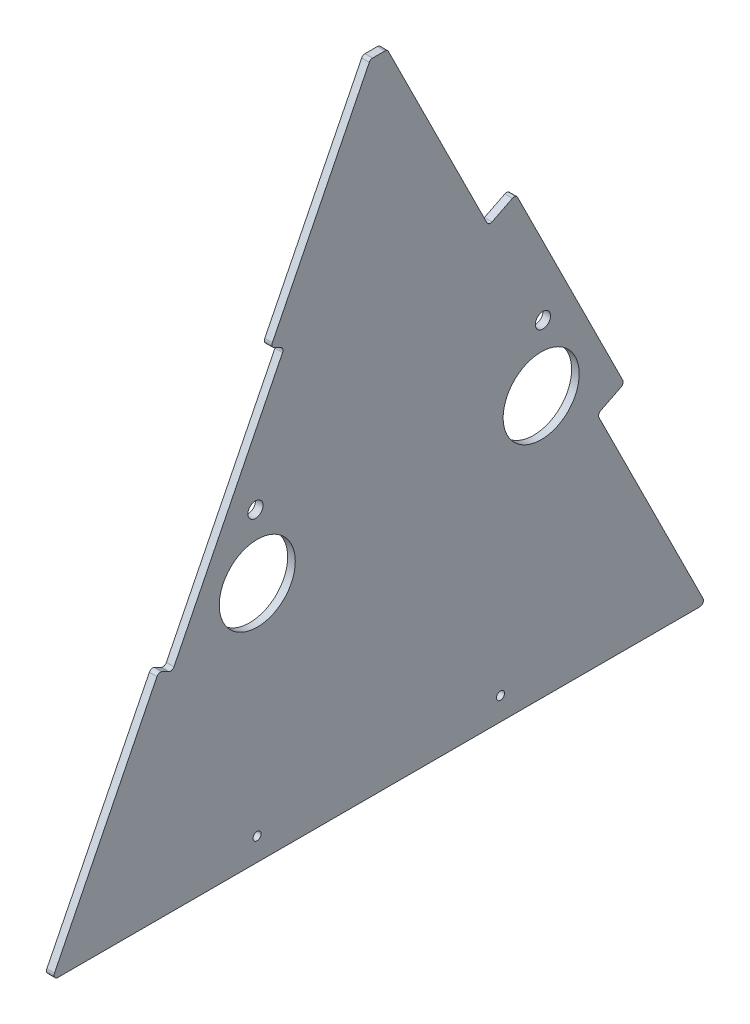
from build123d import *

# Parameters (mm, degrees)
SKETCH1_R           = 3.3734375
SKETCH1_R_2         = 6.35
SKETCH1_R_3         = 31.75
BOSS_EXTRUDE1_DEPTH = 6.35
FILLET1_R           = 3.175


with BuildPart() as part:
    # Sketch1 → Boss-Extrude1 (new body)
    with BuildSketch(Plane(origin=(0, 0, 0), x_dir=(0, 0, -1), z_dir=(1, 0, 0))):
        Polygon((0, 0), (546.1, 0), (455.432604376, 181.850662278), (478.163937161, 193.184086731), (387.496541537, 375.034749008), (364.765208752, 363.701324555), (280.156570264, 533.4), (265.943429736, 533.4), (182.751469304, 366.542741153), (194.117135697, 360.876028927), (100.61638396, 173.342533453), (89.250717567, 179.009245679), align=None)
        with Locations((171.45, 19.05)):
            Circle(SKETCH1_R, mode=Mode.SUBTRACT)
        with Locations((374.65, 19.05)):
            Circle(SKETCH1_R, mode=Mode.SUBTRACT)
        with Locations((410.098906564, 272.775993416)):
            Circle(SKETCH1_R_2, mode=Mode.SUBTRACT)
        with Locations((170.098092613, 255.775856737)):
            Circle(SKETCH1_R_2, mode=Mode.SUBTRACT)
        with Locations((171.579254548, 201.821183313)):
            Circle(SKETCH1_R_3, mode=Mode.SUBTRACT)
        with Locations((408.617744629, 218.821319992)):
            Circle(SKETCH1_R_3, mode=Mode.SUBTRACT)
    extrude(amount=BOSS_EXTRUDE1_DEPTH)

    # Fillet1
    fillet1_edges = [part.edges().sort_by_distance(p)[0] for p in [
        (3.175, 179.009245679, -89.250717567),
        (3.175, 173.342533453, -100.61638396),
        (3.175, 360.876028927, -194.117135697),
        (3.175, 366.542741153, -182.751469304),
        (3.175, 533.4, -265.943429736),
        (3.175, 533.4, -280.156570264),
        (3.175, 363.701324555, -364.765208752),
        (3.175, 375.034749008, -387.496541537),
        (3.175, 193.184086731, -478.163937161),
        (3.175, 181.850662278, -455.432604376),
        (3.175, 0, -546.1),
        (3.175, 0, 0),
    ]]
    fillet(fillet1_edges, radius=FILLET1_R)


solid = part.part
